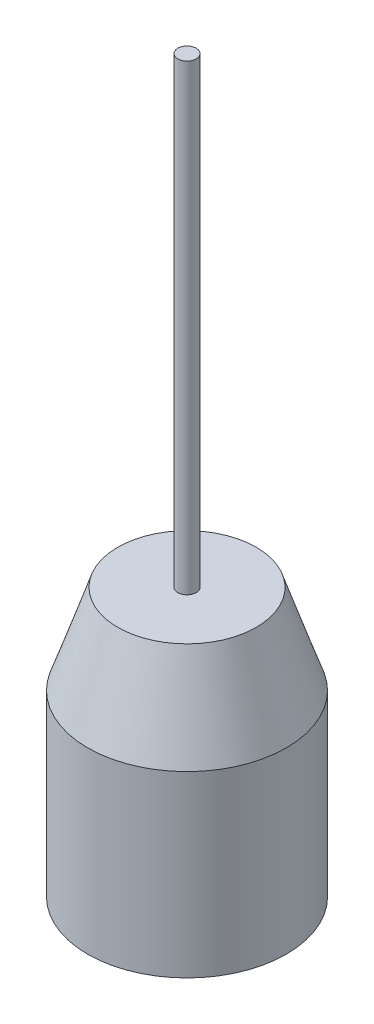
from build123d import *

# Parameters (mm, degrees)
SKETCH1_W                         = 2
SKETCH1_H                         = 100
F_1_2_20_TAPPED_HOLE1_D           = 11.50874
F_1_2_20_TAPPED_HOLE1_DEPTH       = 30
F_1_2_20_TAPPED_HOLE1_CSINK_D     = 13.97
F_1_2_20_TAPPED_HOLE1_CSINK_ANGLE = 90
F_1_2_20_TAPPED_HOLE1_TIP         = 3.45757432


with BuildPart() as part:
    # Sketch1 → Revolve1 (revolve)
    with BuildSketch(Plane.XY):
        Polygon((0, 58), (0, 0), (21.5, 0), (21.5, 38.666666667), (15, 58), (2, 58), align=None)
        with Locations((1, 108)):
            Rectangle(SKETCH1_W, SKETCH1_H)
    revolve(axis=Axis((0, 0, 0), (0, 1, 0)))

    # 1/2-20 Tapped Hole1
    with Locations(Plane(origin=(0, 0, 0), x_dir=(-1, 0, 0), z_dir=(0, -1, 0))):
        with Locations((0, 0)):
            CounterSinkHole(F_1_2_20_TAPPED_HOLE1_D / 2, F_1_2_20_TAPPED_HOLE1_CSINK_D / 2, depth=F_1_2_20_TAPPED_HOLE1_DEPTH, counter_sink_angle=F_1_2_20_TAPPED_HOLE1_CSINK_ANGLE)
            with Locations((0, 0, -(F_1_2_20_TAPPED_HOLE1_DEPTH + F_1_2_20_TAPPED_HOLE1_TIP / 2))):  # 118° drill point
                Cone(0, F_1_2_20_TAPPED_HOLE1_D / 2, F_1_2_20_TAPPED_HOLE1_TIP, mode=Mode.SUBTRACT)


solid = part.part
